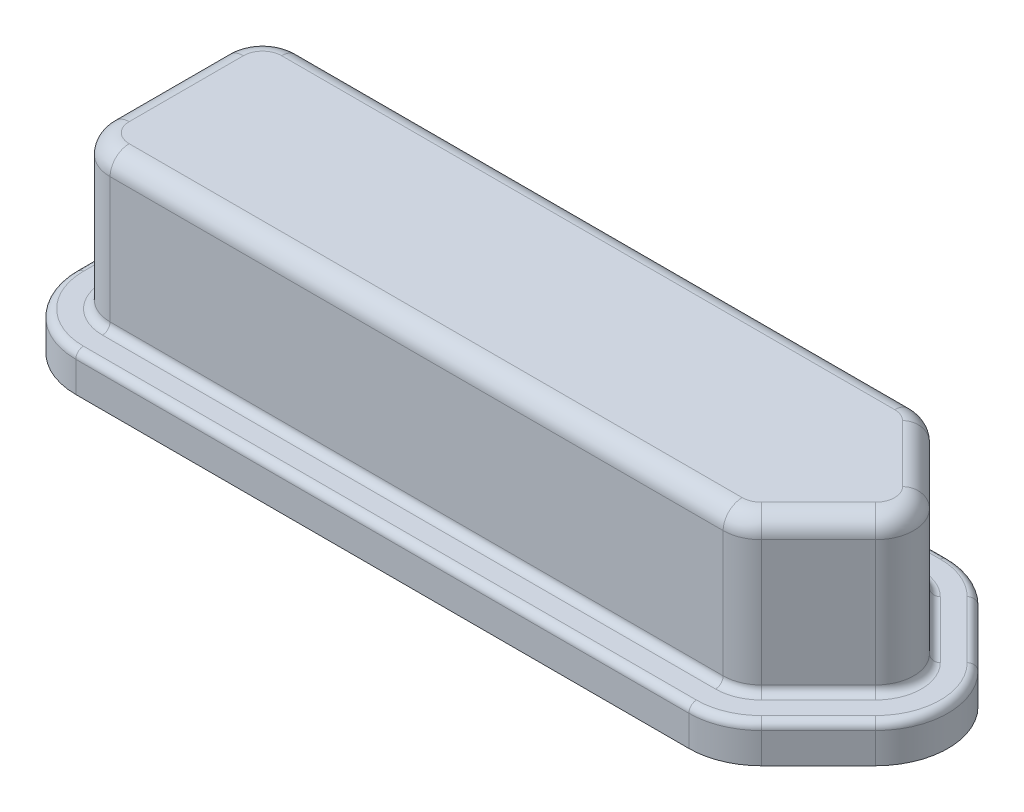
from build123d import *

# Parameters (mm, degrees)
BOSS_EXTRUDE1_DEPTH = 4
FILLET1_R           = 1
FILLET2_R           = 0.5
BOSS_EXTRUDE2_DEPTH = 1
FILLET3_R           = 0.2
FILLET4_R           = 0.2


with BuildPart() as part:
    # Sketch1 → Boss-Extrude1 (new body)
    with BuildSketch(Plane(origin=(0, 0, 0), x_dir=(1, 0, 0), z_dir=(0, 1, 0))):
        Polygon((17.5, 5), (20, 2.5), (17.5, 0), (0, 0), (0, 5), align=None)
    extrude(amount=BOSS_EXTRUDE1_DEPTH)

    # Fillet1
    fillet1_edges = [part.edges().sort_by_distance(p)[0] for p in [
        (0, 2, -5),
        (17.5, 2, -5),
        (20, 2, -2.5),
        (17.5, 2, 0),
        (0, 2, 0),
    ]]
    fillet(fillet1_edges, radius=FILLET1_R)

    # Fillet2
    fillet2_edges = [part.edges().sort_by_distance(p)[0] for p in [
        (9.042893219, 4, -5),
        (18.542893219, 4, -3.957106781),
        (0, 4, -2.5),
        (9.042893219, 4, 0),
        (18.542893219, 4, -1.042893219),
        (19.585786438, 4, -2.5),
        (17.46846987, 4, -0.076120467),
        (0.292893219, 4, -0.292893219),
        (0.292893219, 4, -4.707106781),
        (17.46846987, 4, -4.923879533),
    ]]
    fillet(fillet2_edges, radius=FILLET2_R)

    # Sketch2 → Boss-Extrude2 (add)
    with BuildSketch(Plane.XZ):
        with BuildLine():
            Line((1, -5.9), (17.085786438, -5.9))
            ThreePointArc((17.085786438, -5.9), (17.812884959, -5.755371112), (18.429289322, -5.343502884))
            Line((18.429289322, -5.343502884), (19.929289322, -3.843502884))
            ThreePointArc((19.929289322, -3.843502884), (20.485786438, -2.5), (19.929289322, -1.156497116))
            Line((19.929289322, -1.156497116), (18.429289322, 0.343502884))
            ThreePointArc((18.429289322, 0.343502884), (17.812884959, 0.755371112), (17.085786438, 0.9))
            Line((17.085786438, 0.9), (1, 0.9))
            ThreePointArc((1, 0.9), (-0.343502884, 0.343502884), (-0.9, -1))
            Line((-0.9, -1), (-0.9, -4))
            ThreePointArc((-0.9, -4), (-0.343502884, -5.343502884), (1, -5.9))
        make_face()
    extrude(amount=BOSS_EXTRUDE2_DEPTH)

    # Fillet3
    fillet3_edges = [part.edges().sort_by_distance(p)[0] for p in [
        (9.042893219, 0, -5),
        (0, 0, -2.5),
        (18.542893219, 0, -3.957106781),
        (18.542893219, 0, -1.042893219),
        (9.042893219, 0, 0),
        (19.585786438, 0, -2.5),
        (17.46846987, 0, -0.076120467),
        (0.292893219, 0, -0.292893219),
        (0.292893219, 0, -4.707106781),
        (17.46846987, 0, -4.923879533),
    ]]
    fillet(fillet3_edges, radius=FILLET3_R)

    # Fillet4
    fillet4_edges = [part.edges().sort_by_distance(p)[0] for p in [
        (-0.343502884, 0, -5.343502884),
        (9.042893219, 0, -5.9),
        (17.812884959, 0, -5.755371112),
        (19.179289322, 0, -4.593502884),
        (20.485786438, 0, -2.5),
        (19.179289322, 0, -0.406497116),
        (17.812884959, 0, 0.755371112),
        (9.042893219, 0, 0.9),
        (-0.343502884, 0, 0.343502884),
        (-0.9, 0, -2.5),
    ]]
    fillet(fillet4_edges, radius=FILLET4_R)


solid = part.part
